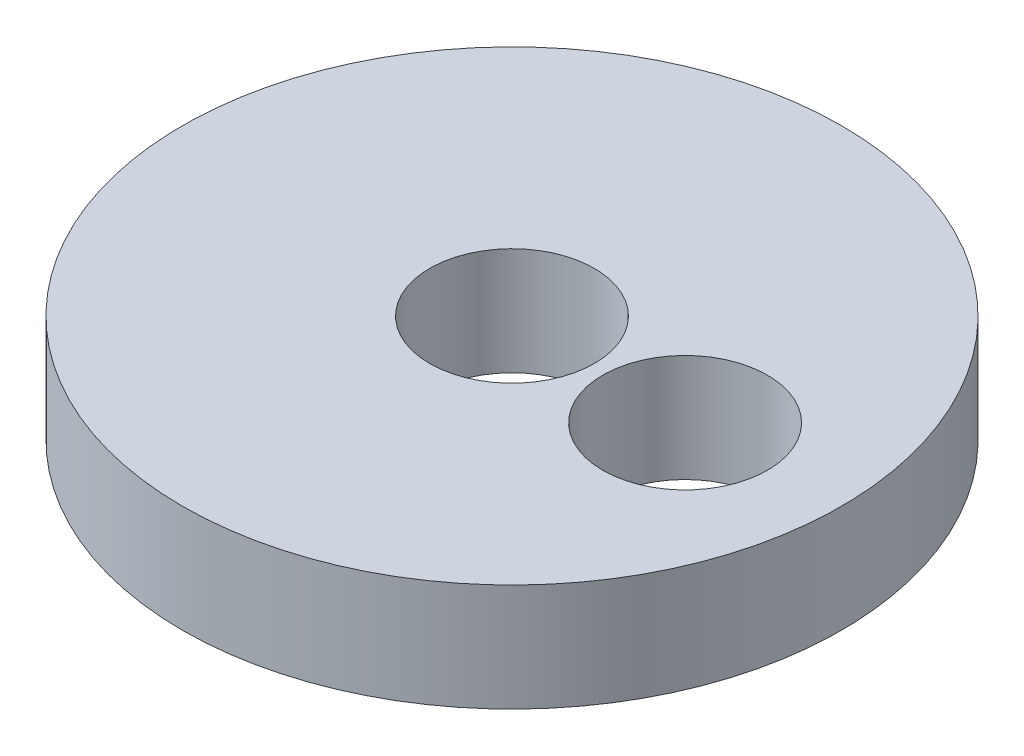
from build123d import *

# Parameters (mm, degrees)
SKETCH1_R           = 9.2
SKETCH1_R_2         = 2.3
BOSS_EXTRUDE1_DEPTH = 3


with BuildPart() as part:
    # Sketch1 → Boss-Extrude1 (new body)
    with BuildSketch(Plane(origin=(0, 0, 0), x_dir=(1, 0, 0), z_dir=(0, 1, 0))):
        Circle(SKETCH1_R)
        with Locations((4.997281989, -0.164841493)):
            Circle(SKETCH1_R_2, mode=Mode.SUBTRACT)
        Circle(SKETCH1_R_2, mode=Mode.SUBTRACT)
    extrude(amount=BOSS_EXTRUDE1_DEPTH)


solid = part.part
